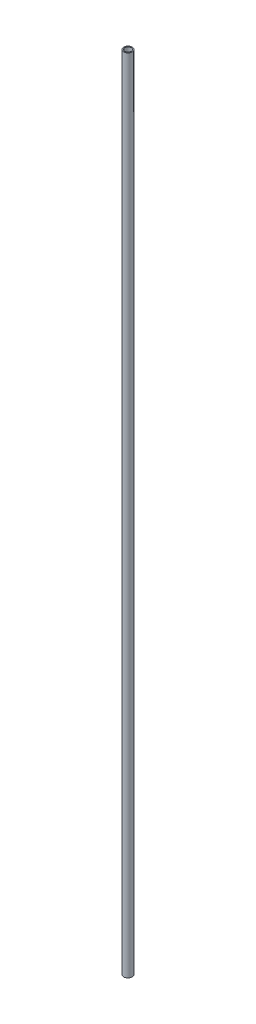
from build123d import *

# Parameters (mm, degrees)
SKETCH1_R           = 10.668
SKETCH1_R_2         = 7.8994
BOSS_EXTRUDE1_DEPTH = 2000


with BuildPart() as part:
    # Sketch1 → Boss-Extrude1 (new body)
    with BuildSketch(Plane(origin=(0, 0, 0), x_dir=(1, 0, 0), z_dir=(0, 1, 0))):
        Circle(SKETCH1_R)
        Circle(SKETCH1_R_2, mode=Mode.SUBTRACT)
    extrude(amount=BOSS_EXTRUDE1_DEPTH)


solid = part.part
